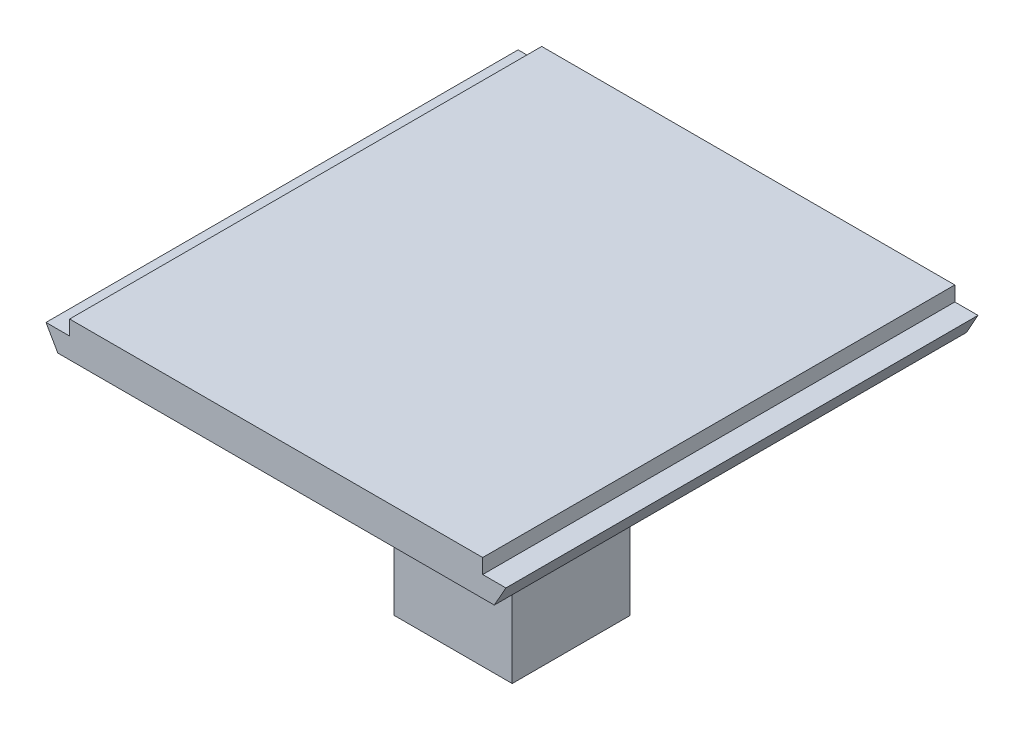
from build123d import *

# Parameters (mm, degrees)
SKETCH1_R           = 6.35
BOSS_EXTRUDE2_DEPTH = 7.62
SKETCH3_R           = 6.35
CUT_EXTRUDE2_DEPTH  = 3.175
SKETCH4_W           = 25.4
SKETCH4_H           = 25.4
BOSS_EXTRUDE3_DEPTH = 50.8
CUT_EXTRUDE4_DEPTH  = 102.6


with BuildPart() as part:
    # Sketch1 → Boss-Extrude2 (new body)
    with BuildSketch(Plane(origin=(0, 0, 0), x_dir=(1, 0, 0), z_dir=(0, 1, 0))):
        with BuildLine():
            Line((-69.85, 50.8), (69.85, 50.8))
            ThreePointArc((69.85, 50.8), (87.810512242, 43.360512242), (95.25, 25.4))
            Line((95.25, 25.4), (95.25, -25.4))
            ThreePointArc((95.25, -25.4), (87.810512242, -43.360512242), (69.85, -50.8))
            Line((69.85, -50.8), (-69.85, -50.8))
            ThreePointArc((-69.85, -50.8), (-87.810512242, -43.360512242), (-95.25, -25.4))
            Line((-95.25, -25.4), (-95.25, 25.4))
            ThreePointArc((-95.25, 25.4), (-87.810512242, 43.360512242), (-69.85, 50.8))
        make_face()
        with Locations((-69.85, 25.4)):
            Circle(SKETCH1_R, mode=Mode.SUBTRACT)
        with Locations((69.85, -25.4)):
            Circle(SKETCH1_R, mode=Mode.SUBTRACT)
        with Locations((69.85, 25.4)):
            Circle(SKETCH1_R, mode=Mode.SUBTRACT)
        with Locations((-69.85, -25.4)):
            Circle(SKETCH1_R, mode=Mode.SUBTRACT)
    extrude(amount=BOSS_EXTRUDE2_DEPTH)

    # Sketch3 → Cut-Extrude2 (cut)
    with BuildSketch(Plane(origin=(0, 7.62, 0), x_dir=(1, 0, 0), z_dir=(0, 1, 0))):
        with BuildLine():
            Line((-44.45, -50.8), (-44.45, 50.8))
            Line((-44.45, 50.8), (-69.85, 50.8))
            ThreePointArc((-69.85, 50.8), (-87.810512242, 43.360512242), (-95.25, 25.4))
            Line((-95.25, 25.4), (-95.25, -25.4))
            ThreePointArc((-95.25, -25.4), (-87.810512242, -43.360512242), (-69.85, -50.8))
            Line((-69.85, -50.8), (-44.45, -50.8))
        make_face()
        with Locations((-69.85, -25.4)):
            Circle(SKETCH3_R, mode=Mode.SUBTRACT)
        with Locations((-69.85, 25.4)):
            Circle(SKETCH3_R, mode=Mode.SUBTRACT)
        with BuildLine():
            Line((69.85, 50.8), (44.45, 50.8))
            Line((44.45, 50.8), (44.45, -50.8))
            Line((44.45, -50.8), (69.85, -50.8))
            ThreePointArc((69.85, -50.8), (87.810512242, -43.360512242), (95.25, -25.4))
            Line((95.25, -25.4), (95.25, 25.4))
            ThreePointArc((95.25, 25.4), (87.810512242, 43.360512242), (69.85, 50.8))
        make_face()
        with Locations((69.85, -25.4)):
            Circle(SKETCH3_R, mode=Mode.SUBTRACT)
        with Locations((69.85, 25.4)):
            Circle(SKETCH3_R, mode=Mode.SUBTRACT)
    extrude(amount=-CUT_EXTRUDE2_DEPTH, mode=Mode.SUBTRACT)

    # Sketch4 → Boss-Extrude3 (add)
    with BuildSketch(Plane.XZ):
        Rectangle(SKETCH4_W, SKETCH4_H)
    extrude(amount=BOSS_EXTRUDE3_DEPTH)

    # Sketch5 → Cut-Extrude4 (cut, through all)
    with BuildSketch(Plane.XY.offset(50.8)):
        Polygon((-49.53, 4.445), (-110.026455684, 4.445), (-110.026455684, 0), (-46.99, 0), align=None)
        Polygon((49.44093255, 4.445), (46.945466275, 0), (109.42401757, 0), (109.42401757, 4.445), align=None)
    extrude(amount=-CUT_EXTRUDE4_DEPTH, mode=Mode.SUBTRACT)


solid = part.part
